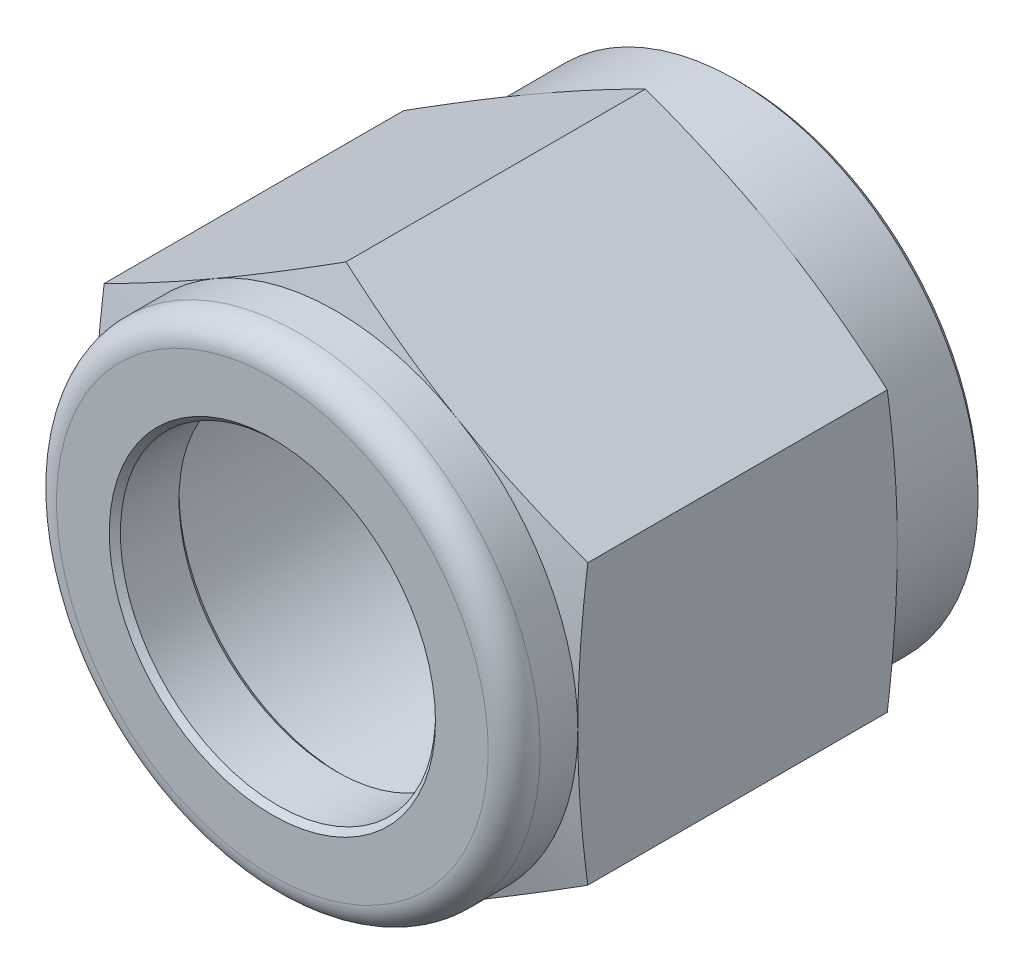
from build123d import *

# Parameters (mm, degrees)
BOSS_EXTRUDE1_DEPTH = 21.5646
FILLET1_R           = 1.1938
CHAMFER1_SIZE       = 0.254
CHAMFER2_SIZE       = 0.254


with BuildPart() as part:
    # Sketch1 → Boss-Extrude1 (new body)
    with BuildSketch(Plane.XY):
        Polygon((0, 12.831609733), (-11.1125, 6.415804866), (-11.1125, -6.415804866), (0, -12.831609733), (11.1125, -6.415804866), (11.1125, 6.415804866), align=None)
    extrude(amount=BOSS_EXTRUDE1_DEPTH)

    # Sketch2 → Cut-Revolve1 (revolve, cut)
    with BuildSketch(Plane(origin=(0, 0, 0), x_dir=(0, 0, -1), z_dir=(1, 0, 0))):
        Polygon((-21.5646, 14.550719465), (-21.5646, 11.1125), (-18.6436, 11.1125), (-18.182965935, 12.831609733), (-4.423034065, 12.831609733), (-3.9624, 11.1125), (0, 11.1125), (0, 14.550719465), align=None)
        with BuildLine():
            Line((-21.5646, 7.239), (-21.5646, 0))
            Line((-21.5646, 0), (0, 0))
            Line((0, 0), (0, 8.751666378))
            Line((0, 8.751666378), (-18.1102, 8.751666378))
            ThreePointArc((-18.1102, 8.751666378), (-18.289805122, 8.6772715), (-18.3642, 8.497666378))
            Line((-18.3642, 8.497666378), (-18.3642, 7.239))
            Line((-18.3642, 7.239), (-21.5646, 7.239))
        make_face()
    revolve(axis=Axis((0, 0, 0), (0, 0, 1)), mode=Mode.SUBTRACT)

    # Fillet1
    fillet1_edges = [part.edges().sort_by_distance(p)[0] for p in [
        (0, -11.1125, 21.5646),
    ]]
    fillet(fillet1_edges, radius=FILLET1_R)

    # Chamfer1
    chamfer1_edges = [part.edges().sort_by_distance(p)[0] for p in [
        (0, -11.1125, 0),
    ]]
    chamfer(chamfer1_edges, length=CHAMFER1_SIZE)

    # Chamfer2
    chamfer2_edges = [part.edges().sort_by_distance(p)[0] for p in [
        (0, -7.239, 21.5646),
        (0, -7.239, 18.3642),
    ]]
    chamfer(chamfer2_edges, length=CHAMFER2_SIZE)


solid = part.part
